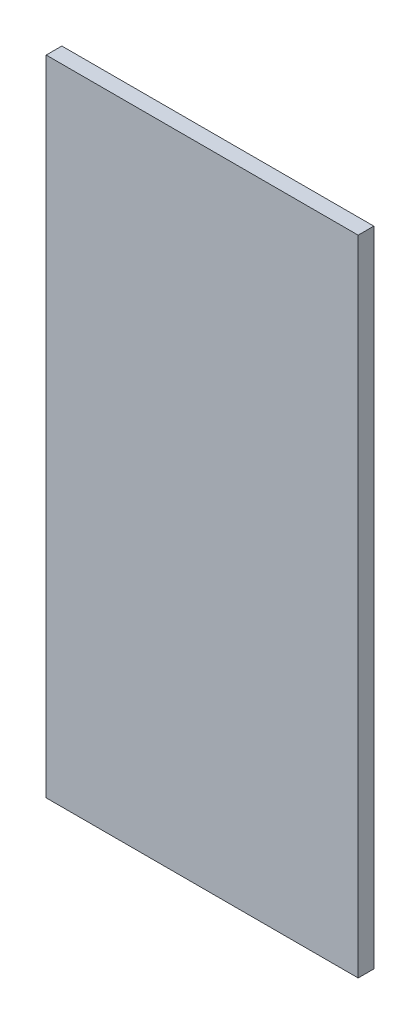
from build123d import *

# Parameters (mm, degrees)
SKETCH1_W           = 114.3
SKETCH1_H           = 235.712
BOSS_EXTRUDE1_DEPTH = 5.732800066


with BuildPart() as part:
    # Sketch1 → Boss-Extrude1 (new body)
    with BuildSketch(Plane.XY):
        Rectangle(SKETCH1_W, SKETCH1_H)
    extrude(amount=BOSS_EXTRUDE1_DEPTH)


solid = part.part
